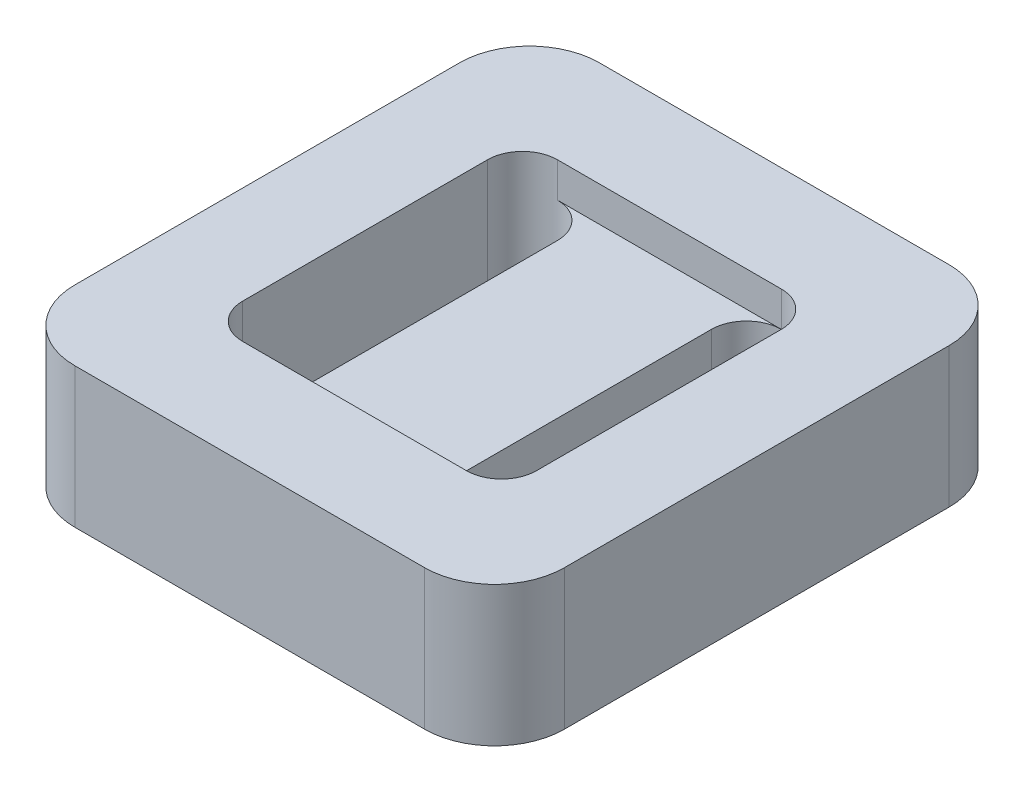
from build123d import *

# Parameters (mm, degrees)
BOSS_EXTRUDE1_DEPTH = 20
CUT_EXTRUDE1_DEPTH  = 5


with BuildPart() as part:
    # Sketch1 → Boss-Extrude1 (new body)
    with BuildSketch(Plane(origin=(0, 0, 0), x_dir=(1, 0, 0), z_dir=(0, 1, 0))):
        with BuildLine():
            Line((-25, -37.5), (25, -37.5))
            ThreePointArc((25, -37.5), (32.071067812, -34.571067812), (35, -27.5))
            Line((35, -27.5), (35, 27.5))
            ThreePointArc((35, 27.5), (32.071067812, 34.571067812), (25, 37.5))
            Line((25, 37.5), (-25, 37.5))
            ThreePointArc((-25, 37.5), (-32.071067812, 34.571067812), (-35, 27.5))
            Line((-35, 27.5), (-35, -27.5))
            ThreePointArc((-35, -27.5), (-32.071067812, -34.571067812), (-25, -37.5))
        make_face()
        with BuildLine():
            Line((-21, -17.5), (-21, 17.5))
            ThreePointArc((-21, 17.5), (-16, 22.5), (-11, 17.5))
            Line((-11, 17.5), (-11, -17.5))
            ThreePointArc((-11, -17.5), (-16, -22.5), (-21, -17.5))
        make_face(mode=Mode.SUBTRACT)
        with BuildLine():
            Line((21, -17.5), (21, 17.5))
            ThreePointArc((21, 17.5), (16, 22.5), (11, 17.5))
            Line((11, 17.5), (11, -17.5))
            ThreePointArc((11, -17.5), (16, -22.5), (21, -17.5))
        make_face(mode=Mode.SUBTRACT)
    extrude(amount=BOSS_EXTRUDE1_DEPTH)

    # Sketch2 → Cut-Extrude1 (cut)
    with BuildSketch(Plane(origin=(0, 20, 0), x_dir=(1, 0, 0), z_dir=(0, 1, 0))):
        with BuildLine():
            Line((-16, -22.5), (16, -22.5))
            ThreePointArc((16, -22.5), (12.464466094, -21.035533906), (11, -17.5))
            Line((11, -17.5), (11, 17.5))
            ThreePointArc((11, 17.5), (12.464466094, 21.035533906), (16, 22.5))
            Line((16, 22.5), (-16, 22.5))
            ThreePointArc((-16, 22.5), (-12.464466094, 21.035533906), (-11, 17.5))
            Line((-11, 17.5), (-11, -17.5))
            ThreePointArc((-11, -17.5), (-12.464466094, -21.035533906), (-16, -22.5))
        make_face()
    extrude(amount=-CUT_EXTRUDE1_DEPTH, mode=Mode.SUBTRACT)


solid = part.part
